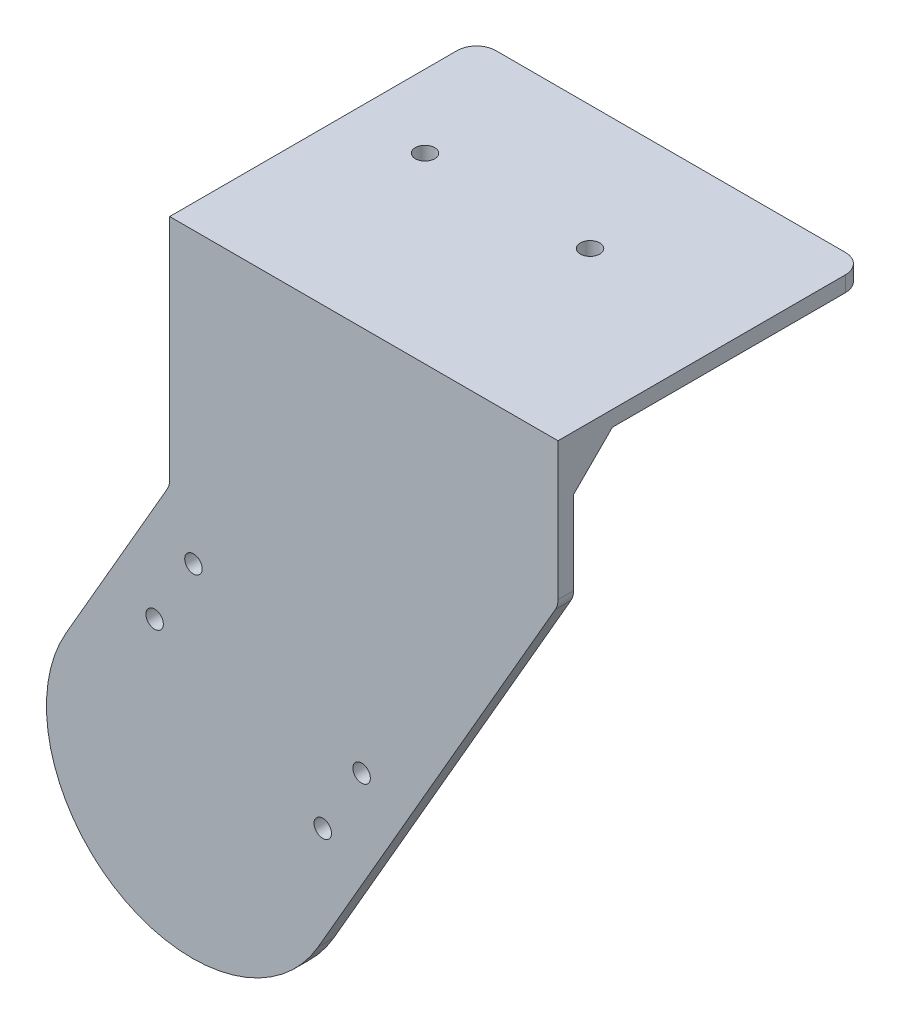
from build123d import *

# Parameters (mm, degrees)
BOSS_EXTRUDE1_DEPTH = 8
SKETCH4_W           = 150
SKETCH4_H           = 8
BOSS_EXTRUDE2_DEPTH = 200
CHAMFER1_SIZE       = 20
CUT_EXTRUDE1_REACH  = 327
SKETCH5_R           = 5
CUT_EXTRUDE3_REACH  = 10
SKETCH6_R           = 4.5
FILLET1_R           = 10


with BuildPart() as part:
    # Sketch1 → Boss-Extrude1 (new body)
    with BuildSketch(Plane.XY):
        with BuildLine():
            Line((-64.951905284, 37.5), (-11.547005384, 130))
            Line((-11.547005384, 130), (-11.547005384, 250))
            Line((-11.547005384, 250), (188.452994616, 250))
            Line((188.452994616, 250), (188.452994616, 176.410161514))
            Line((188.452994616, 176.410161514), (64.951905284, -37.5))
            ThreePointArc((64.951905284, -37.5), (-37.5, -64.951905284), (-64.951905284, 37.5))
        make_face()
    extrude(amount=BOSS_EXTRUDE1_DEPTH)

    # Sketch4 → Boss-Extrude2 (add)
    with BuildSketch(Plane.ZY.offset(11.547005384)):
        with Locations((-75, 246)):
            Rectangle(SKETCH4_W, SKETCH4_H)
    extrude(amount=-BOSS_EXTRUDE2_DEPTH)

    # Chamfer1
    chamfer1_edges = [part.edges().sort_by_distance(p)[0] for p in [
        (88.452994616, 242, 0),
    ]]
    chamfer(chamfer1_edges, length=CHAMFER1_SIZE)

    # Sketch5 → Cut-Extrude1 (cut, up to next)
    with BuildSketch(Plane(origin=(0, 250, 0), x_dir=(1, 0, 0), z_dir=(0, 1, 0)), mode=Mode.PRIVATE) as cut_extrude1_sk1:
        with Locations((110.952994616, 86)):
            Circle(SKETCH5_R)
    cut_extrude1_tool1 = extrude(cut_extrude1_sk1.sketch, amount=-CUT_EXTRUDE1_REACH, mode=Mode.PRIVATE) & part.part
    add(cut_extrude1_tool1.solids().sort_by_distance((110.952995, 250, -86))[0], mode=Mode.SUBTRACT)
    # Sketch5 → Cut-Extrude1 (cut, up to next)
    with BuildSketch(Plane(origin=(0, 250, 0), x_dir=(1, 0, 0), z_dir=(0, 1, 0)), mode=Mode.PRIVATE) as cut_extrude1_sk2:
        with Locations((25.952994616, 86)):
            Circle(SKETCH5_R)
    cut_extrude1_tool2 = extrude(cut_extrude1_sk2.sketch, amount=-CUT_EXTRUDE1_REACH, mode=Mode.PRIVATE) & part.part
    add(cut_extrude1_tool2.solids().sort_by_distance((25.952995, 250, -86))[0], mode=Mode.SUBTRACT)

    # Sketch6 → Cut-Extrude3 (cut, up to next)
    with BuildSketch(Plane.XY, mode=Mode.PRIVATE) as cut_extrude3_sk1:
        with Locations((87.301270189, 51.210235533)):
            Circle(SKETCH6_R)
    cut_extrude3_tool1 = extrude(cut_extrude3_sk1.sketch, amount=CUT_EXTRUDE3_REACH, mode=Mode.PRIVATE) & part.part
    add(cut_extrude3_tool1.solids().sort_by_distance((87.30127, 51.210236, 0))[0], mode=Mode.SUBTRACT)
    # Sketch6 → Cut-Extrude3 (cut, up to next)
    with BuildSketch(Plane.XY, mode=Mode.PRIVATE) as cut_extrude3_sk2:
        with Locations((67.301270189, 16.569219382)):
            Circle(SKETCH6_R)
    cut_extrude3_tool2 = extrude(cut_extrude3_sk2.sketch, amount=CUT_EXTRUDE3_REACH, mode=Mode.PRIVATE) & part.part
    add(cut_extrude3_tool2.solids().sort_by_distance((67.30127, 16.569219, 0))[0], mode=Mode.SUBTRACT)
    # Sketch6 → Cut-Extrude3 (cut, up to next)
    with BuildSketch(Plane.XY, mode=Mode.PRIVATE) as cut_extrude3_sk3:
        with Locations((-19.301270189, 66.569219382)):
            Circle(SKETCH6_R)
    cut_extrude3_tool3 = extrude(cut_extrude3_sk3.sketch, amount=CUT_EXTRUDE3_REACH, mode=Mode.PRIVATE) & part.part
    add(cut_extrude3_tool3.solids().sort_by_distance((-19.30127, 66.569219, 0))[0], mode=Mode.SUBTRACT)
    # Sketch6 → Cut-Extrude3 (cut, up to next)
    with BuildSketch(Plane.XY, mode=Mode.PRIVATE) as cut_extrude3_sk4:
        with Locations((0.698729811, 101.210235533)):
            Circle(SKETCH6_R)
    cut_extrude3_tool4 = extrude(cut_extrude3_sk4.sketch, amount=CUT_EXTRUDE3_REACH, mode=Mode.PRIVATE) & part.part
    add(cut_extrude3_tool4.solids().sort_by_distance((0.69873, 101.210236, 0))[0], mode=Mode.SUBTRACT)

    # Fillet1
    fillet1_edges = [part.edges().sort_by_distance(p)[0] for p in [
        (-11.547005384, 130, 4),
        (188.452994616, 176.410161514, 4),
        (-11.547005384, 246, -150),
        (188.452994616, 246, -150),
    ]]
    fillet(fillet1_edges, radius=FILLET1_R)


solid = part.part
